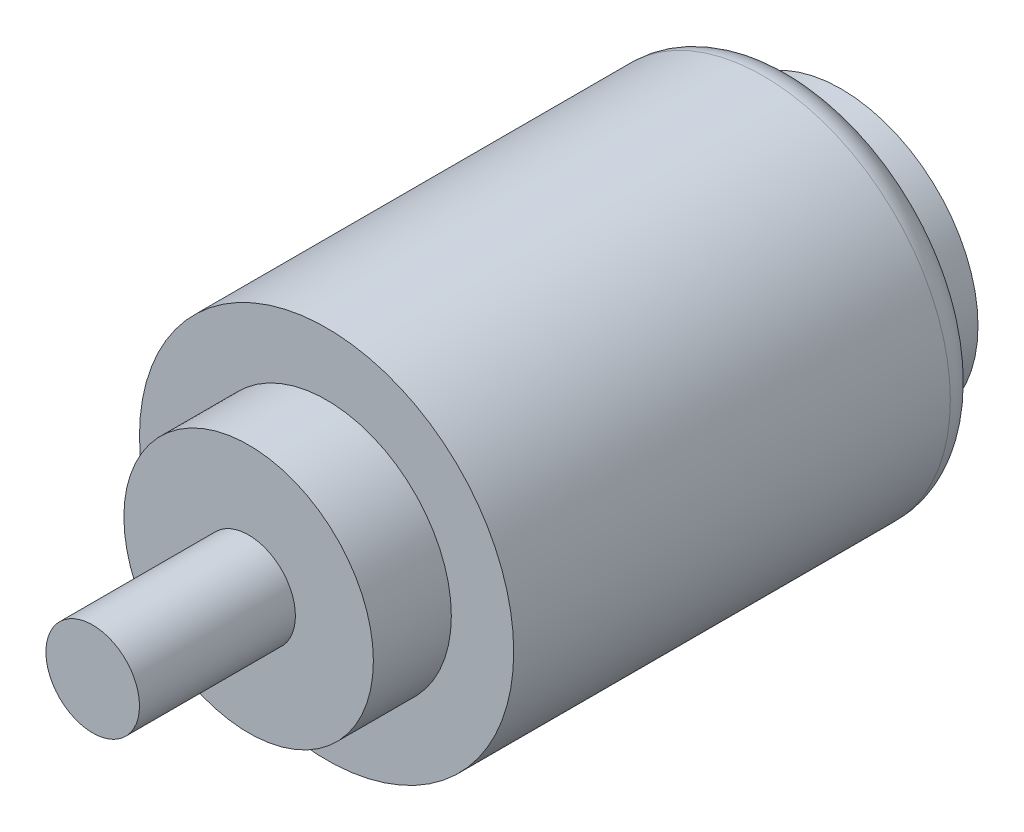
from build123d import *

# Parameters (mm, degrees)
SKETCH1_R           = 12
BOSS_EXTRUDE1_DEPTH = 30
SKETCH2_R           = 8
BOSS_EXTRUDE2_DEPTH = 5
SKETCH4_R           = 1.579295677
CUT_EXTRUDE3_DEPTH  = 3
SKETCH5_R           = 3
BOSS_EXTRUDE3_DEPTH = 10
SKETCH6_R           = 8.773986351
BOSS_EXTRUDE4_DEPTH = 3
FILLET1_R           = 2


with BuildPart() as part:
    # Sketch1 → Boss-Extrude1 (new body)
    with BuildSketch(Plane.XY):
        with Locations((5.178689325, -6.92509434)):
            Circle(SKETCH1_R)
    extrude(amount=BOSS_EXTRUDE1_DEPTH)

    # Sketch2 → Boss-Extrude2 (add)
    with BuildSketch(Plane.XY.offset(30)):
        with Locations((5.178689325, -6.92509434)):
            Circle(SKETCH2_R)
    extrude(amount=BOSS_EXTRUDE2_DEPTH)

    # Sketch4 → Cut-Extrude3 (cut)
    with BuildSketch(Plane.XY.offset(35)):
        with Locations((5.178689325, 2.995609984)):
            Circle(SKETCH4_R)
        with Locations((15.099393648, -6.92509434)):
            Circle(SKETCH4_R)
        with Locations((5.178689325, -16.845798663)):
            Circle(SKETCH4_R)
        with Locations((-4.742014998, -6.92509434)):
            Circle(SKETCH4_R)
    extrude(amount=-CUT_EXTRUDE3_DEPTH, mode=Mode.SUBTRACT)

    # Sketch5 → Boss-Extrude3 (add)
    with BuildSketch(Plane.XY.offset(35)):
        with Locations((5.178689325, -6.92509434)):
            Circle(SKETCH5_R)
    extrude(amount=BOSS_EXTRUDE3_DEPTH)

    # Sketch6 → Boss-Extrude4 (add)
    with BuildSketch(Plane(origin=(0, 0, 0), x_dir=(-1, 0, 0), z_dir=(0, 0, -1))):
        with Locations((-5.178689325, -6.92509434)):
            Circle(SKETCH6_R)
    extrude(amount=BOSS_EXTRUDE4_DEPTH)

    # Fillet1
    fillet1_edges = [part.edges().sort_by_distance(p)[0] for p in [
        (-6.821310675, -6.92509434, 0),
    ]]
    fillet(fillet1_edges, radius=FILLET1_R)


solid = part.part
